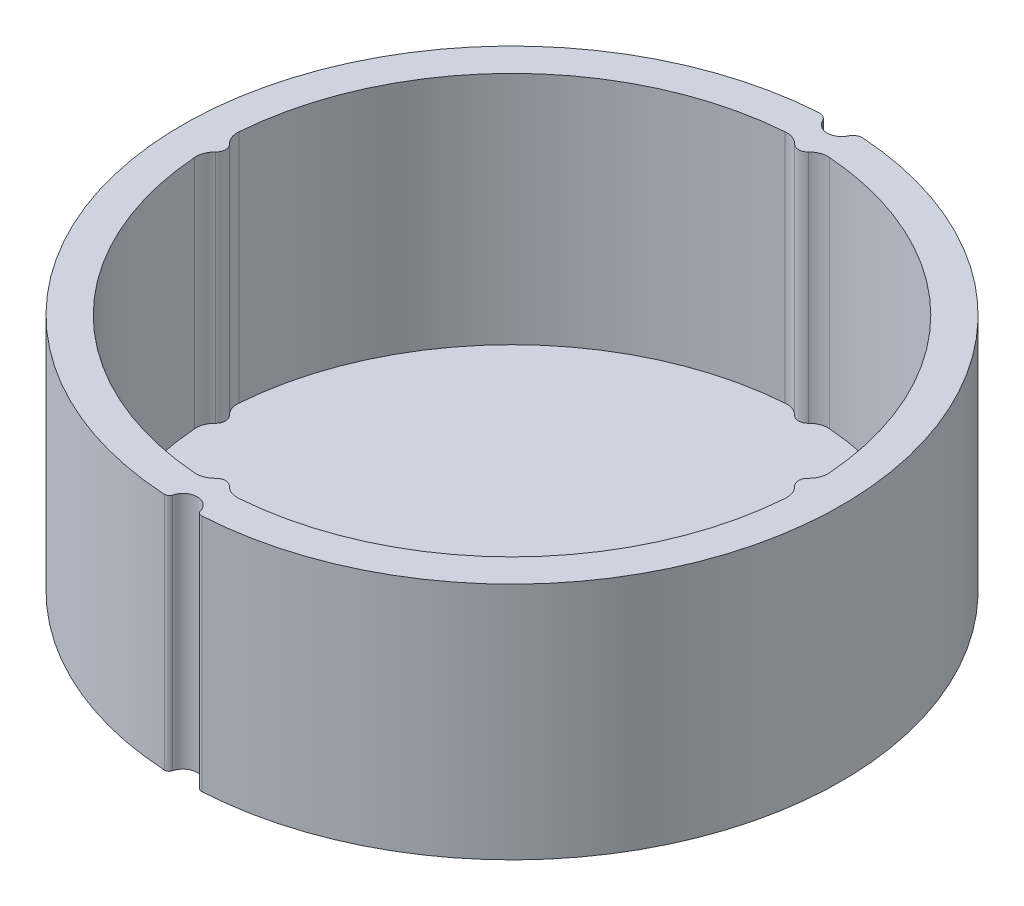
from build123d import *

# Parameters (mm, degrees)
BOSS_EXTRUDE1_DEPTH = 25
CUT_EXTRUDE2_DEPTH  = 55.786493398
BOSS_EXTRUDE2_DEPTH = 0.4


with BuildPart() as part:
    # Sketch1 → Boss-Extrude1 (new body)
    with BuildSketch(Plane(origin=(0, 0, 0), x_dir=(1, 0, 0), z_dir=(0, 1, 0))):
        with BuildLine():
            ThreePointArc((1.451818925, -34.068556857), (1.641248992, -34.346908706), (1.964225605, -34.442038138))
            ThreePointArc((1.964225605, -34.442038138), (26.591847487, -21.978073076), (34.198225299, 4.555174015))
            ThreePointArc((34.198225299, 4.555174015), (23.590291339, 25.176355888), (2.324135821, 34.423627607))
            ThreePointArc((2.324135821, 34.423627607), (1.751838249, 34.289058819), (1.354061739, 33.856153382))
            ThreePointArc((1.354061739, 33.856153382), (0, 33.001534515), (-1.354061739, 33.856153382))
            ThreePointArc((-1.354061739, 33.856153382), (-1.751838249, 34.289058819), (-2.324135821, 34.423627607))
            ThreePointArc((-2.324135821, 34.423627607), (-23.590291339, 25.176355888), (-34.198225299, 4.555174015))
            ThreePointArc((-34.198225299, 4.555174015), (-26.591847487, -21.978073076), (-1.964225605, -34.442038138))
            ThreePointArc((-1.964225605, -34.442038138), (-1.641248992, -34.346908706), (-1.451818925, -34.068556857))
            ThreePointArc((-1.451818925, -34.068556857), (0, -32.945679925), (1.451818925, -34.068556857))
        make_face()
        with BuildLine():
            Line((-2.417, 3.787737139), (0, 3.787737139))
            Line((0, 3.787737139), (2.417, 3.787737139))
            ThreePointArc((2.417, 3.787737139), (0, -4.489512172), (-2.417, 3.787737139))
        make_face(mode=Mode.SUBTRACT)
    extrude(amount=BOSS_EXTRUDE1_DEPTH)

    # Sketch2 → Cut-Extrude2 (cut, through all)
    with BuildSketch(Plane(origin=(0, 0, 0), x_dir=(1, 0, 0), z_dir=(0, 1, 0))):
        with BuildLine():
            ThreePointArc((-30.913793103, -2.310280493), (-21.920310217, -21.920310217), (-2.310280493, -30.913793103))
            ThreePointArc((-2.310280493, -30.913793103), (-1.447519283, -30.787674087), (-0.720410046, -30.306451613))
            ThreePointArc((-0.720410046, -30.306451613), (0, -30), (0.720410046, -30.306451613))
            ThreePointArc((0.720410046, -30.306451613), (1.447519283, -30.787674087), (2.310280493, -30.913793103))
            ThreePointArc((2.310280493, -30.913793103), (21.920310217, -21.920310217), (30.913793103, -2.310280493))
            ThreePointArc((30.913793103, -2.310280493), (30.787674087, -1.447519283), (30.306451613, -0.720410046))
            ThreePointArc((30.306451613, -0.720410046), (30, 0), (30.306451613, 0.720410046))
            ThreePointArc((30.306451613, 0.720410046), (30.787674087, 1.447519283), (30.913793103, 2.310280493))
            ThreePointArc((30.913793103, 2.310280493), (21.920310217, 21.920310217), (2.310280493, 30.913793103))
            ThreePointArc((2.310280493, 30.913793103), (1.447519283, 30.787674087), (0.720410046, 30.306451613))
            ThreePointArc((0.720410046, 30.306451613), (0, 30), (-0.720410046, 30.306451613))
            ThreePointArc((-0.720410046, 30.306451613), (-1.447519283, 30.787674087), (-2.310280493, 30.913793103))
            ThreePointArc((-2.310280493, 30.913793103), (-21.920310217, 21.920310217), (-30.913793103, 2.310280493))
            ThreePointArc((-30.913793103, 2.310280493), (-30.787674087, 1.447519283), (-30.306451613, 0.720410046))
            ThreePointArc((-30.306451613, 0.720410046), (-30, 0), (-30.306451613, -0.720410046))
            ThreePointArc((-30.306451613, -0.720410046), (-30.787674087, -1.447519283), (-30.913793103, -2.310280493))
        make_face()
    extrude(amount=CUT_EXTRUDE2_DEPTH, mode=Mode.SUBTRACT)

    # Sketch2_2 → Boss-Extrude2 (add)
    with BuildSketch(Plane(origin=(0, 0, 0), x_dir=(1, 0, 0), z_dir=(0, 1, 0))):
        with BuildLine():
            ThreePointArc((-30.913793103, -2.310280493), (-21.920310217, -21.920310217), (-2.310280493, -30.913793103))
            ThreePointArc((-2.310280493, -30.913793103), (-1.447519283, -30.787674087), (-0.720410046, -30.306451613))
            ThreePointArc((-0.720410046, -30.306451613), (0, -30), (0.720410046, -30.306451613))
            ThreePointArc((0.720410046, -30.306451613), (1.447519283, -30.787674087), (2.310280493, -30.913793103))
            ThreePointArc((2.310280493, -30.913793103), (21.920310217, -21.920310217), (30.913793103, -2.310280493))
            ThreePointArc((30.913793103, -2.310280493), (30.787674087, -1.447519283), (30.306451613, -0.720410046))
            ThreePointArc((30.306451613, -0.720410046), (30, 0), (30.306451613, 0.720410046))
            ThreePointArc((30.306451613, 0.720410046), (30.787674087, 1.447519283), (30.913793103, 2.310280493))
            ThreePointArc((30.913793103, 2.310280493), (21.920310217, 21.920310217), (2.310280493, 30.913793103))
            ThreePointArc((2.310280493, 30.913793103), (1.447519283, 30.787674087), (0.720410046, 30.306451613))
            ThreePointArc((0.720410046, 30.306451613), (0, 30), (-0.720410046, 30.306451613))
            ThreePointArc((-0.720410046, 30.306451613), (-1.447519283, 30.787674087), (-2.310280493, 30.913793103))
            ThreePointArc((-2.310280493, 30.913793103), (-21.920310217, 21.920310217), (-30.913793103, 2.310280493))
            ThreePointArc((-30.913793103, 2.310280493), (-30.787674087, 1.447519283), (-30.306451613, 0.720410046))
            ThreePointArc((-30.306451613, 0.720410046), (-30, 0), (-30.306451613, -0.720410046))
            ThreePointArc((-30.306451613, -0.720410046), (-30.787674087, -1.447519283), (-30.913793103, -2.310280493))
        make_face()
    extrude(amount=BOSS_EXTRUDE2_DEPTH)


solid = part.part
